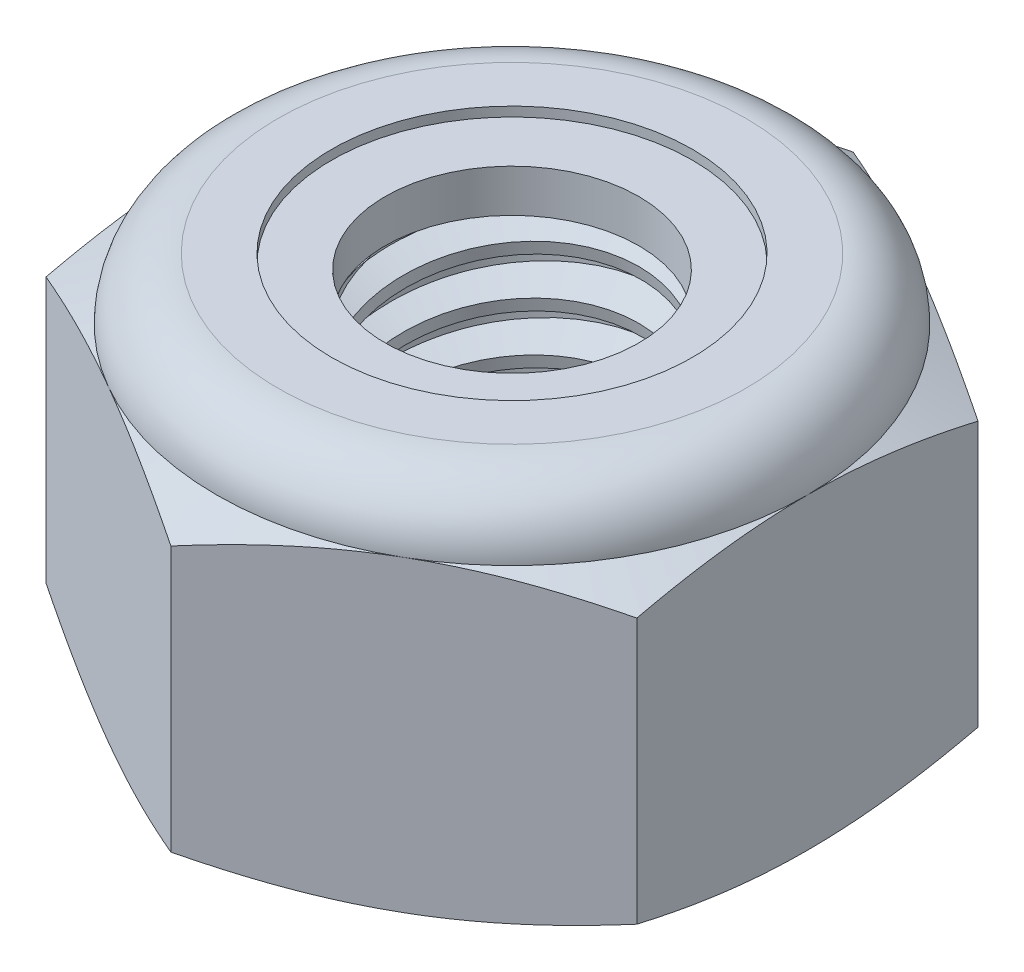
from build123d import *

# Parameters (mm, degrees)
EXTRUDE1_DEPTH      = 5.953125
SKETCH2_W           = 2.413
SKETCH2_H           = 5.953125
LPATTERN1_COUNT     = 8
LPATTERN1_PITCH     = 0.79375
LPATTERN1_COL_COUNT = 2
LPATTERN1_COL_PITCH = 0.79375


with BuildPart() as part:
    # Sketch1 → Extrude1 (new body)
    with BuildSketch(Plane(origin=(0, 0, 0), x_dir=(1, 0, 0), z_dir=(0, 1, 0))):
        Polygon((0, 5.499261314), (-4.7625, 2.749630657), (-4.7625, -2.749630657), (0, -5.499261314), (4.7625, -2.749630657), (4.7625, 2.749630657), align=None)
    extrude(amount=EXTRUDE1_DEPTH)

    # Sketch4 → Cut-Revolve2 (revolve, cut)
    with BuildSketch(Plane(origin=(0, 0, 0), x_dir=(0, 0, -1), z_dir=(1, 0, 0))):
        Polygon((0, 5.953125), (2.413, 5.953125), (2.045424837, 5.781721887), (2.045424837, 0.171403113), (2.413, 0), (0, 0), align=None)
    revolve(axis=Axis((0, 5.953125, 0), (0, 1, 0)), mode=Mode.SUBTRACT)


with BuildPart() as body_2:
    # Sketch2 → Revolve1 (revolve)
    with BuildSketch(Plane(origin=(0, 0, 0), x_dir=(0, 0, -1), z_dir=(1, 0, 0))):
        with Locations((1.2065, 2.9765625)):
            Rectangle(SKETCH2_W, SKETCH2_H)
    revolve(axis=Axis((0, -2.413, 0), (0, 1, 0)))

    # Sketch3 → Cut-Revolve1 (revolve, cut)
    with BuildSketch(Plane(origin=(0, 0, 0), x_dir=(0, 0, -1), z_dir=(1, 0, 0))):
        Polygon((2.429102527, 5.855221635), (2.541820218, 5.169898076), (2.077629892, 5.344930502), (2.045424837, 5.540737233), align=None)
    cut_revolve1 = revolve(axis=Axis((0, 5.953125, 0.139697061), (0, -0.986742581, -0.162293188)), mode=Mode.SUBTRACT)

    # LPattern1: Cut-Revolve1 ×8
    with Locations(*[(0, -i * LPATTERN1_PITCH, 0) for i in range(1, LPATTERN1_COUNT)]):
        add(cut_revolve1, mode=Mode.SUBTRACT)

    # LPattern1 col: Cut-Revolve1 ×2
    with Locations(*[(0, i * LPATTERN1_COL_PITCH, 0) for i in range(1, LPATTERN1_COL_COUNT)]):
        add(cut_revolve1, mode=Mode.SUBTRACT)


with BuildPart() as part_1:
    add(part.part)

    # Combine1: cut body 2
    add(body_2.part, mode=Mode.SUBTRACT)

    # Sketch5 → Cut-Revolve3 (revolve, cut)
    with BuildSketch(Plane(origin=(0, 0, 0), x_dir=(0, 0, -1), z_dir=(1, 0, 0))):
        with BuildLine():
            Line((0, 0), (4.7625, 0))
            Line((4.7625, 0), (5.499261314, 0.343557443))
            Line((5.499261314, 0.343557443), (5.499261314, 4.617380057))
            Line((5.499261314, 4.617380057), (4.7625, 4.9609375))
            ThreePointArc((4.7625, 4.9609375), (4.471895009, 5.662520009), (3.7703125, 5.953125))
            Line((3.7703125, 5.953125), (3.7703125, 7.223125))
            Line((3.7703125, 7.223125), (6.769261314, 7.223125))
            Line((6.769261314, 7.223125), (6.769261314, -1.27))
            Line((6.769261314, -1.27), (0, -1.27))
            Line((0, -1.27), (0, 0))
        make_face()
    revolve(axis=Axis((0, 0, 0), (0, 1, 0)), mode=Mode.SUBTRACT)

    # Sketch6 → Cut-Revolve4 (revolve, cut)
    with BuildSketch(Plane(origin=(0, 0, 0), x_dir=(0, 0, -1), z_dir=(1, 0, 0))):
        with BuildLine():
            Line((0, 4.9609375), (4.6101, 4.9609375))
            ThreePointArc((4.6101, 4.9609375), (4.364131936, 5.554756936), (3.7703125, 5.800725))
            Line((3.7703125, 5.800725), (2.907868669, 5.800725))
            Line((2.907868669, 5.800725), (2.907868669, 7.223125))
            Line((2.907868669, 7.223125), (0, 7.223125))
            Line((0, 7.223125), (0, 4.9609375))
        make_face()
    revolve(axis=Axis((0, 7.223125, 0), (0, 1, 0)), mode=Mode.SUBTRACT)


with BuildPart() as body_2_2:
    # Sketch7 → Revolve2 (revolve)
    with BuildSketch(Plane(origin=(0, 0, 0), x_dir=(0, 0, -1), z_dir=(1, 0, 0))):
        with BuildLine():
            Line((2.045424837, 5.0371375), (4.530088408, 5.0371375))
            ThreePointArc((4.530088408, 5.0371375), (4.282601726, 5.527175629), (3.7703125, 5.724525))
            Line((3.7703125, 5.724525), (2.045424837, 5.724525))
            Line((2.045424837, 5.724525), (2.045424837, 5.0371375))
        make_face()
    revolve(axis=Axis((0, 5.0371375, 0), (0, 1, 0)))


solid = Compound([part_1.part, body_2_2.part])
